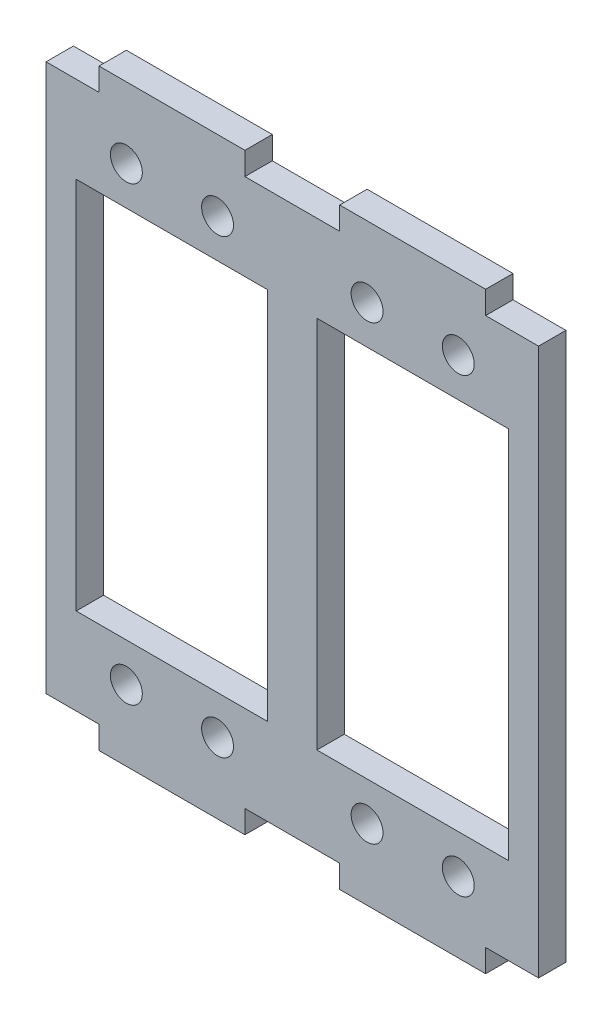
from build123d import *

# Parameters (mm, degrees)
SKETCH_1_W      = 54
SKETCH_1_H      = 60
SKETCH_1_R      = 1.75
SKETCH_1_W_2    = 21
SKETCH_1_H_2    = 41
SKETCH_1_W_3    = 16
SKETCH_1_H_3    = 2.5
EXTRUDE_1_DEPTH = 3


with BuildPart() as part:
    # Эскиз1 → Бобышка-Вытянуть1 (new body)
    with BuildSketch(Plane.XY):
        with Locations((0, -10.1)):
            Rectangle(SKETCH_1_W, SKETCH_1_H)
        with Locations((-18.19729, 14.65)):
            Circle(SKETCH_1_R, mode=Mode.SUBTRACT)
        with Locations((-8.19729, 14.65)):
            Circle(SKETCH_1_R, mode=Mode.SUBTRACT)
        with Locations((8.19729, 14.65)):
            Circle(SKETCH_1_R, mode=Mode.SUBTRACT)
        with Locations((18.19729, 14.65)):
            Circle(SKETCH_1_R, mode=Mode.SUBTRACT)
        with Locations((18.19729, -34.85)):
            Circle(SKETCH_1_R, mode=Mode.SUBTRACT)
        with Locations((8.19729, -34.85)):
            Circle(SKETCH_1_R, mode=Mode.SUBTRACT)
        with Locations((-8.197262, -34.85)):
            Circle(SKETCH_1_R, mode=Mode.SUBTRACT)
        with Locations((-18.19729, -34.85)):
            Circle(SKETCH_1_R, mode=Mode.SUBTRACT)
        with Locations((-13.19729, -10.1)):
            Rectangle(SKETCH_1_W_2, SKETCH_1_H_2, mode=Mode.SUBTRACT)
        with Locations((13.19729, -10.1)):
            Rectangle(SKETCH_1_W_2, SKETCH_1_H_2, mode=Mode.SUBTRACT)
        with Locations((-13.19729, 21.15)):
            Rectangle(SKETCH_1_W_3, SKETCH_1_H_3)
        with Locations((13.19729, 21.15)):
            Rectangle(SKETCH_1_W_3, SKETCH_1_H_3)
        with Locations((13.19729, -41.35)):
            Rectangle(SKETCH_1_W_3, SKETCH_1_H_3)
        with Locations((-13.19729, -41.35)):
            Rectangle(SKETCH_1_W_3, SKETCH_1_H_3)
    extrude(amount=-EXTRUDE_1_DEPTH)


solid = part.part
